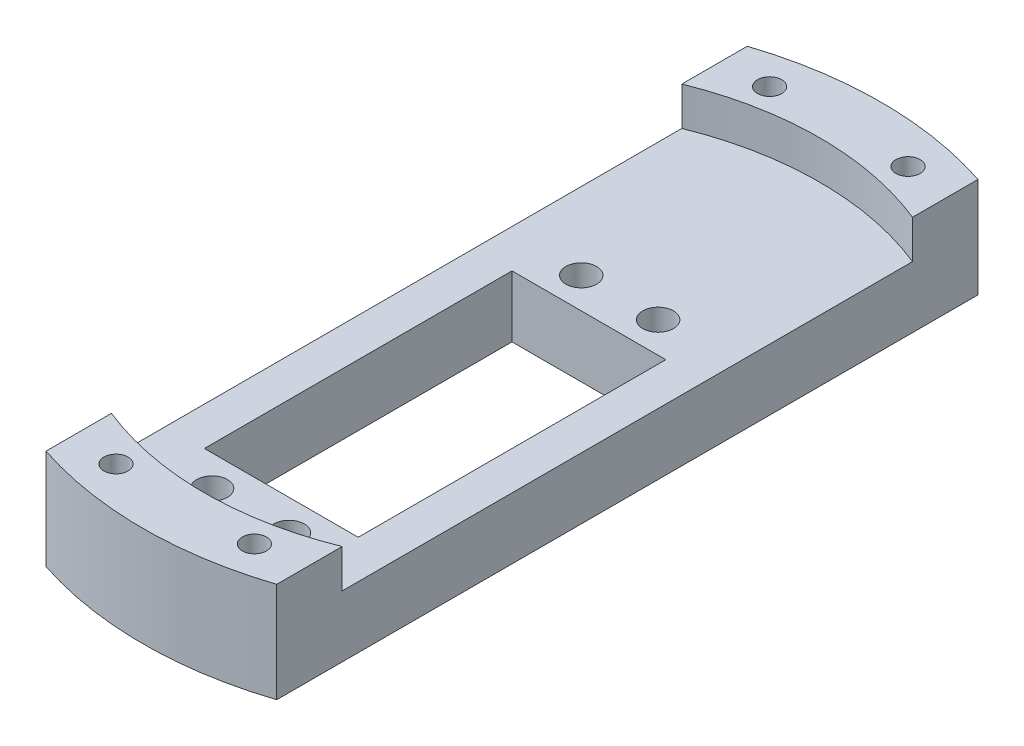
from build123d import *

# Parameters (mm, degrees)
SKETCH_1_R                  = 2
SKETCH_1_W                  = 20
SKETCH_1_H                  = 40
EXTRUDE_1_DEPTH             = 8
EXTRUDE_2_DEPTH             = 5
HOLE_WIZARD_M31_D           = 3.15
PATTERN_LINEAR_1_COUNT      = 2
PATTERN_LINEAR_1_PITCH      = 18
PATTERN_LINEAR_1_COUNT_DIR2 = 2
PATTERN_LINEAR_1_PITCH_DIR2 = 85


with BuildPart() as part:
    # Эскиз1 → Бобышка-Вытянуть1 (new body)
    with BuildSketch(Plane(origin=(0, 0, 0), x_dir=(1, 0, 0), z_dir=(0, 1, 0))):
        with BuildLine():
            Line((-15, -45.596052461), (-15, 45.596052461))
            ThreePointArc((-15, 45.596052461), (0, 48), (15, 45.596052461))
            Line((15, 45.596052461), (15, -45.596052461))
            ThreePointArc((15, -45.596052461), (0, -48), (-15, -45.596052461))
        make_face()
        with Locations((-5, -34)):
            Circle(SKETCH_1_R, mode=Mode.SUBTRACT)
        with Locations((5, -34)):
            Circle(SKETCH_1_R, mode=Mode.SUBTRACT)
        with Locations((5, 14)):
            Circle(SKETCH_1_R, mode=Mode.SUBTRACT)
        with Locations((-5, 14)):
            Circle(SKETCH_1_R, mode=Mode.SUBTRACT)
        with Locations((0, -10)):
            Rectangle(SKETCH_1_W, SKETCH_1_H, mode=Mode.SUBTRACT)
    extrude(amount=EXTRUDE_1_DEPTH)

    # Эскиз2 → Бобышка-Вытянуть2 (add)
    with BuildSketch(Plane(origin=(0, 8, 0), x_dir=(1, 0, 0), z_dir=(0, 1, 0))):
        with BuildLine():
            Line((-15, 37.080992435), (-15, 45.596052461))
            ThreePointArc((-15, 45.596052461), (0, 48), (15, 45.596052461))
            Line((15, 45.596052461), (15, 37.080992435))
            ThreePointArc((15, 37.080992435), (0, 40), (-15, 37.080992435))
        make_face()
        with BuildLine():
            Line((-15, -37.080992435), (-15, -45.596052461))
            ThreePointArc((-15, -45.596052461), (0, -48), (15, -45.596052461))
            Line((15, -45.596052461), (15, -37.080992435))
            ThreePointArc((15, -37.080992435), (0, -40), (-15, -37.080992435))
        make_face()
    extrude(amount=EXTRUDE_2_DEPTH)

    # Сверло под метчик  спиральное M31 (through all)
    with Locations(Plane(origin=(0, 13, 0), x_dir=(1, 0, 0), z_dir=(0, 1, 0))):
        with Locations((-9, -42.5)):
            hole_wizard_m31 = Hole(HOLE_WIZARD_M31_D / 2)

    # Линейный массив1: Hole Wizard M31 2 × 2
    with Locations(*[(i * PATTERN_LINEAR_1_PITCH, 0, -j * PATTERN_LINEAR_1_PITCH_DIR2) for i in range(PATTERN_LINEAR_1_COUNT) for j in range(PATTERN_LINEAR_1_COUNT_DIR2) if (i, j) != (0, 0)]):
        add(hole_wizard_m31, mode=Mode.SUBTRACT)


solid = part.part
